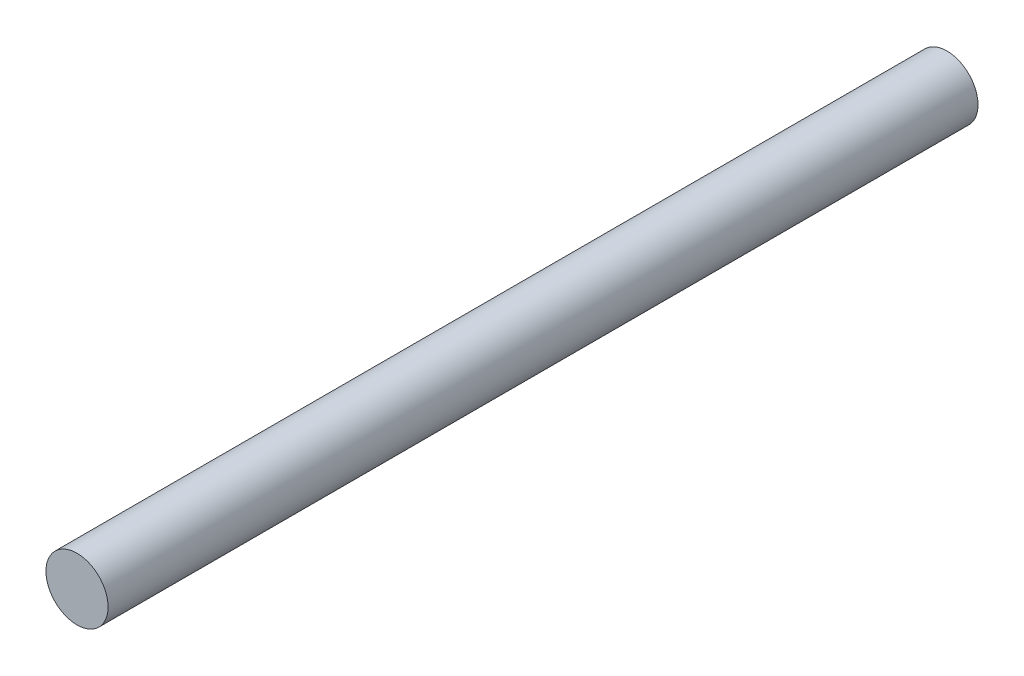
from build123d import *

# Parameters (mm, degrees)
SKETCH1_R           = 3
BOSS_EXTRUDE1_DEPTH = 84


with BuildPart() as part:
    # Sketch1 → Boss-Extrude1 (new body)
    with BuildSketch(Plane.XY):
        Circle(SKETCH1_R)
    extrude(amount=BOSS_EXTRUDE1_DEPTH)


solid = part.part
